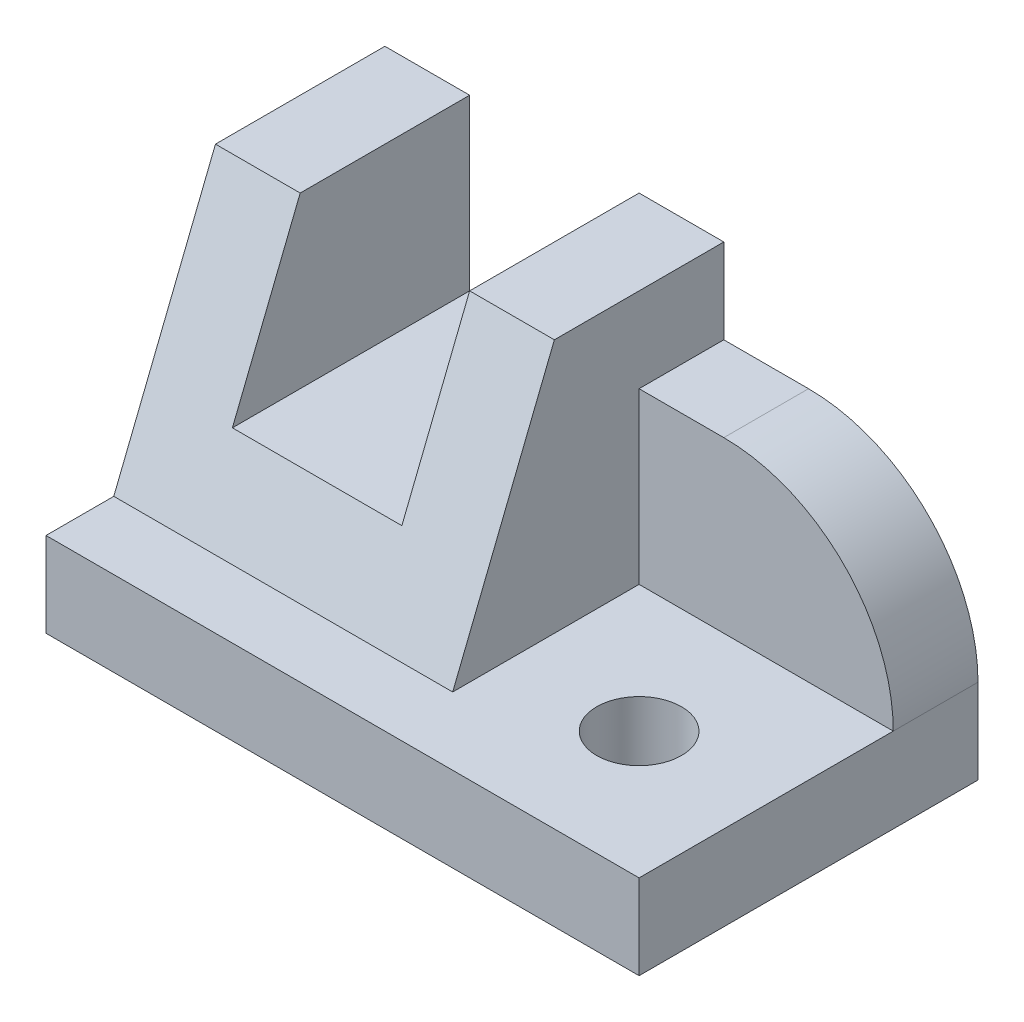
from build123d import *

# Parameters (mm, degrees)
BOSS_EXTRUDE1_DEPTH            = 40
SKETCH2_W                      = 40
SKETCH2_H                      = 30
BOSS_EXTRUDE2_DEPTH            = 20
BOSS_EXTRUDE3_DEPTH            = 30
CUT_EXTRUDE1_DEPTH             = 30
SKETCH5_W                      = 70
SKETCH5_H                      = 40
BOSS_EXTRUDE4_DEPTH            = 10
SKETCH6_W                      = 20
SKETCH6_H                      = 20
CUT_EXTRUDE2_DEPTH             = 41
F_10_0_10_DIAMETER_HOLE1_D     = 10
F_10_0_10_DIAMETER_HOLE1_DEPTH = 40
FILLET1_R                      = 20


with BuildPart() as part:
    # Sketch1 → Boss-Extrude1 (new body)
    with BuildSketch(Plane(origin=(0, 0, 0), x_dir=(0, -1, 0), z_dir=(-1, 0, 0))):
        Polygon((-10, -8), (-40, -20), (-10, -20), align=None)
    extrude(amount=-BOSS_EXTRUDE1_DEPTH)

    # Sketch2 → Boss-Extrude2 (add)
    with BuildSketch(Plane(origin=(0, 0, -20), x_dir=(-1, 0, 0), z_dir=(0, 0, -1))):
        with Locations((-20, 25)):
            Rectangle(SKETCH2_W, SKETCH2_H)
    extrude(amount=BOSS_EXTRUDE2_DEPTH)

    # Sketch3 → Boss-Extrude3 (add)
    with BuildSketch(Plane(origin=(40, 0, 0), x_dir=(0, 0, -1), z_dir=(1, 0, 0))):
        Polygon((40, 10), (0, 10), (20, 40), (40, 40), align=None)
    extrude(amount=BOSS_EXTRUDE3_DEPTH)

    # Sketch4 → Cut-Extrude1 (cut)
    with BuildSketch(Plane(origin=(70, 0, 0), x_dir=(0, 0, -1), z_dir=(1, 0, 0))):
        Polygon((20, 40), (0, 10), (30, 10), (30, 30), (40, 30), (40, 40), align=None)
    extrude(amount=-CUT_EXTRUDE1_DEPTH, mode=Mode.SUBTRACT)

    # Sketch5 → Boss-Extrude4 (add)
    with BuildSketch(Plane.XZ.offset(-10)):
        with Locations((35, -20)):
            Rectangle(SKETCH5_W, SKETCH5_H)
    extrude(amount=BOSS_EXTRUDE4_DEPTH)

    # Sketch6 → Cut-Extrude2 (cut, through all)
    with BuildSketch(Plane(origin=(0, 0, -40), x_dir=(-1, 0, 0), z_dir=(0, 0, -1))):
        with Locations((-20, 30)):
            Rectangle(SKETCH6_W, SKETCH6_H)
    extrude(amount=-CUT_EXTRUDE2_DEPTH, mode=Mode.SUBTRACT)

    # Ø10.0 (10) Diameter Hole1
    with Locations(Plane(origin=(0, 0, 0), x_dir=(-1, 0, 0), z_dir=(0, -1, 0))):
        with Locations((-55, 15)):
            Hole(F_10_0_10_DIAMETER_HOLE1_D / 2, depth=F_10_0_10_DIAMETER_HOLE1_DEPTH)

    # Fillet1
    fillet1_edges = [part.edges().sort_by_distance(p)[0] for p in [
        (70, 30, -35),
    ]]
    fillet(fillet1_edges, radius=FILLET1_R)


solid = part.part
